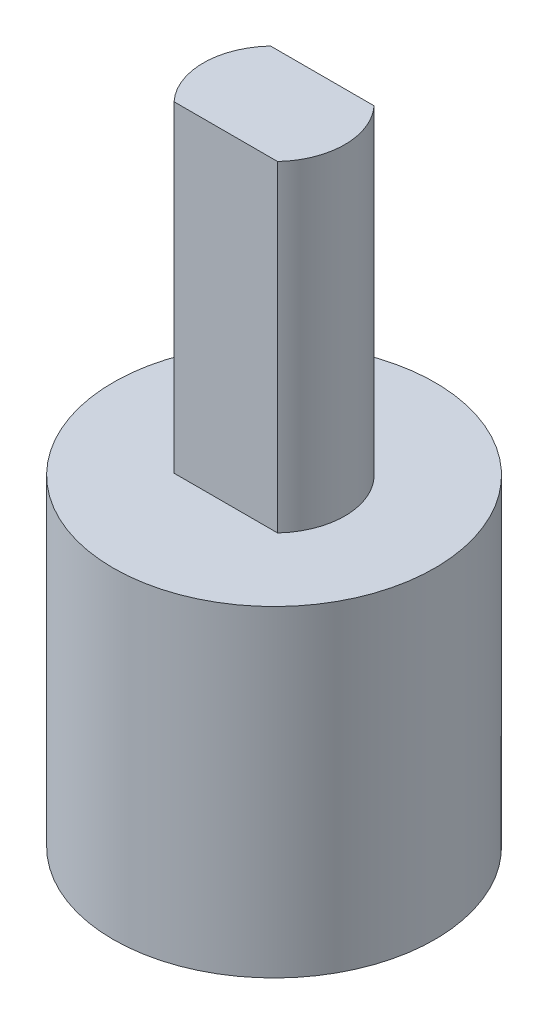
from build123d import *

# Parameters (mm, degrees)
SKETCH1_R           = 5
BOSS_EXTRUDE1_DEPTH = 8
SKETCH2_R           = 5
BOSS_EXTRUDE2_DEPTH = 2
BOSS_EXTRUDE3_DEPTH = 10


with BuildPart() as part:
    # Sketch1 → Boss-Extrude1 (new body)
    with BuildSketch(Plane(origin=(0, 0, 0), x_dir=(1, 0, 0), z_dir=(0, 1, 0))):
        Circle(SKETCH1_R)
        with BuildLine():
            Line((-2, 1.5), (2, 1.5))
            ThreePointArc((2, 1.5), (0, -2.5), (-2, 1.5))
        make_face(mode=Mode.SUBTRACT)
    extrude(amount=BOSS_EXTRUDE1_DEPTH)

    # Sketch2 → Boss-Extrude2 (add)
    with BuildSketch(Plane(origin=(0, 8, 0), x_dir=(1, 0, 0), z_dir=(0, 1, 0))):
        Circle(SKETCH2_R)
    extrude(amount=BOSS_EXTRUDE2_DEPTH)

    # Sketch3 → Boss-Extrude3 (add)
    with BuildSketch(Plane(origin=(0, 10, 0), x_dir=(1, 0, 0), z_dir=(0, 1, 0))):
        with BuildLine():
            Line((-1.609347694, 1.5), (1.609347694, 1.5))
            ThreePointArc((1.609347694, 1.5), (2.2, 0), (1.609347694, -1.5))
            Line((1.609347694, -1.5), (-1.609347694, -1.5))
            ThreePointArc((-1.609347694, -1.5), (-2.2, 0), (-1.609347694, 1.5))
        make_face()
    extrude(amount=BOSS_EXTRUDE3_DEPTH)


solid = part.part
